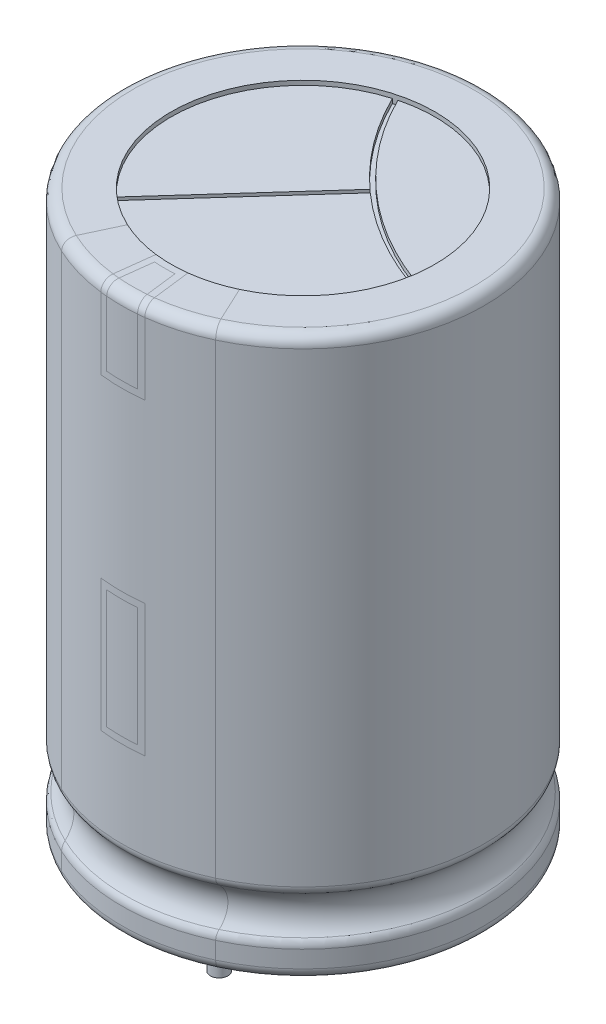
from build123d import *

# Parameters (mm, degrees)
SZKIC2_R                      = 6
WYTNIJ_WYCI_GNI_CIE1_DEPTH    = 0.2
WYTNIJ_WYCI_GNI_CIE2_DEPTH    = 0.2
SZKIC4_R                      = 6
WYTNIJ_WYCI_GNI_CIE3_DEPTH    = 0.5
SZKIC10_R                     = 0.4
DODANIE_WYCI_GNI_CIE1_DEPTH   = 4
DODANIE_WYCI_GNI_CIE1_2_DEPTH = 4
DODANIE_WYCI_GNI_CIE2_DEPTH   = 1.2
DODANIE_WYCI_GNI_CIE2_2_DEPTH = 1.2
SZKIC12_R                     = 4
SZKIC12_R_2                   = 3
WYTNIJ_WYCI_GNI_CIE4_DEPTH    = 0.3
ZAOKR_GLENIE1_R               = 0.05
ZAOKR_GLENIE2_R               = 0.05


with BuildPart() as part:
    # Szkic1 → Obrót1 (revolve)
    with BuildSketch(Plane(origin=(0, 0, 0), x_dir=(0, 0, -1), z_dir=(1, 0, 0))):
        with BuildLine():
            Line((0, 0), (7.75, 0))
            ThreePointArc((7.75, 0), (8.103553391, 0.146446609), (8.25, 0.5))
            Line((8.25, 0.5), (8.25, 1.275255129))
            ThreePointArc((8.25, 1.275255129), (8.21291005, 1.464237365), (8.107142857, 1.625182235))
            ThreePointArc((8.107142857, 1.625182235), (7.75, 2.5), (8.107142857, 3.374817765))
            ThreePointArc((8.107142857, 3.374817765), (8.21291005, 3.535762635), (8.25, 3.724744871))
            Line((8.25, 3.724744871), (8.25, 24.9))
            ThreePointArc((8.25, 24.9), (8.103553391, 25.253553391), (7.75, 25.4))
            Line((7.75, 25.4), (0, 25.4))
            Line((0, 25.4), (0, 0))
        make_face()
    revolve(axis=Axis((0, 25.4, 0), (0, -1, 0)))

    # Szkic2 → Wytnij-wyciągnięcie1 (cut)
    with BuildSketch(Plane(origin=(0, 25.4, 0), x_dir=(1, 0, 0), z_dir=(0, 1, 0))):
        Circle(SZKIC2_R)
    extrude(amount=-WYTNIJ_WYCI_GNI_CIE1_DEPTH, mode=Mode.SUBTRACT)

    # Szkic3 → Wytnij-wyciągnięcie2 (cut)
    with BuildSketch(Plane(origin=(0, 25.2, 0), x_dir=(1, 0, 0), z_dir=(0, 1, 0))):
        with BuildLine():
            Line((1.368369919, 1.670607479), (-4.086590726, -4.39315106))
            ThreePointArc((-4.086590726, -4.39315106), (-4.01280392, -4.460650704), (-3.937902369, -4.526911191))
            Line((-3.937902369, -4.526911191), (1.517058276, 1.536847349))
            ThreePointArc((1.517058276, 1.536847349), (3.58668768, 0.022863948), (5.90219726, -1.078919601))
            ThreePointArc((5.90219726, -1.078919601), (5.919652159, -0.978630837), (5.935403101, -0.878060377))
            ThreePointArc((5.935403101, -0.878060377), (1.576230137, 1.752144438), (-1.498827426, 5.80977765))
            ThreePointArc((-1.498827426, 5.80977765), (-1.59717725, 5.783513191), (-1.69506733, 5.755583962))
            ThreePointArc((-1.69506733, 5.755583962), (-0.355341103, 3.569115293), (1.368369919, 1.670607479))
        make_face()
    extrude(amount=-WYTNIJ_WYCI_GNI_CIE2_DEPTH, mode=Mode.SUBTRACT)

    # Szkic4 → Wytnij-wyciągnięcie3 (cut)
    with BuildSketch(Plane.XZ):
        Circle(SZKIC4_R)
    extrude(amount=-WYTNIJ_WYCI_GNI_CIE3_DEPTH, mode=Mode.SUBTRACT)


with BuildPart() as body_2:
    # Szkic10 → Dodanie-wyciągnięcie1 (new body)
    with BuildSketch(Plane(origin=(0, 0.5, 0), x_dir=(-1, 0, 0), z_dir=(0, -1, 0))):
        with Locations((0, -3.81)):
            Circle(SZKIC10_R)
    extrude(amount=DODANIE_WYCI_GNI_CIE1_DEPTH)


with BuildPart() as body_3:
    # Szkic10 → Dodanie-wyci_gni_cie1 2 (new body)
    with BuildSketch(Plane(origin=(0, 0.5, 0), x_dir=(-1, 0, 0), z_dir=(0, -1, 0))):
        with Locations((0, 3.81)):
            Circle(SZKIC10_R)
    extrude(amount=DODANIE_WYCI_GNI_CIE1_2_DEPTH)


with BuildPart() as body_4:
    # Szkic11 → Dodanie-wyciągnięcie2 (new body)
    with BuildSketch(Plane(origin=(0, 0.5, 0), x_dir=(-1, 0, 0), z_dir=(0, -1, 0))):
        with BuildLine():
            Line((-0.934090555, -3.628920082), (-1.259054317, -4.52175088))
            ThreePointArc((-1.259054317, -4.52175088), (-1.706791557, -4.988117075), (-2.353073698, -4.971221597))
            ThreePointArc((-2.353073698, -4.971221597), (-4.089677513, -3.677572276), (-5.192304065, -1.813829787))
            ThreePointArc((-5.192304065, -1.813829787), (-5.08938791, -1.086893009), (-4.437059837, -0.75))
            Line((-4.437059837, -0.75), (4.437059837, -0.75))
            ThreePointArc((4.437059837, -0.75), (5.08938791, -1.086893009), (5.192304065, -1.813829787))
            ThreePointArc((5.192304065, -1.813829787), (4.089677513, -3.677572276), (2.353073698, -4.971221597))
            ThreePointArc((2.353073698, -4.971221597), (1.706791557, -4.988117075), (1.259054317, -4.52175088))
            Line((1.259054317, -4.52175088), (0.934090555, -3.628920082))
            ThreePointArc((0.934090555, -3.628920082), (0, -2.974862784), (-0.934090555, -3.628920082))
        make_face()
    extrude(amount=DODANIE_WYCI_GNI_CIE2_DEPTH)


with BuildPart() as body_5:
    # Szkic11 → Dodanie-wyci_gni_cie2 2 (new body)
    with BuildSketch(Plane(origin=(0, 0.5, 0), x_dir=(-1, 0, 0), z_dir=(0, -1, 0))):
        with BuildLine():
            Line((-4.437059837, 0.75), (4.437059837, 0.75))
            ThreePointArc((4.437059837, 0.75), (5.08938791, 1.086893009), (5.192304065, 1.813829787))
            ThreePointArc((5.192304065, 1.813829787), (4.089677513, 3.677572276), (2.353073698, 4.971221597))
            ThreePointArc((2.353073698, 4.971221597), (1.706791557, 4.988117075), (1.259054317, 4.52175088))
            Line((1.259054317, 4.52175088), (0.935314887, 3.632283908))
            ThreePointArc((0.935314887, 3.632283908), (0.002495095, 2.978510498), (-0.931462726, 3.630657127))
            Line((-0.931462726, 3.630657127), (-1.258254713, 4.523665192))
            ThreePointArc((-1.258254713, 4.523665192), (-1.706047593, 4.988940616), (-2.351578607, 4.971929008))
            ThreePointArc((-2.351578607, 4.971929008), (-4.089124492, 3.678187174), (-5.192304065, 1.813829787))
            ThreePointArc((-5.192304065, 1.813829787), (-5.08938791, 1.086893009), (-4.437059837, 0.75))
        make_face()
    extrude(amount=DODANIE_WYCI_GNI_CIE2_2_DEPTH)


with BuildPart() as wytnij_wyci_gni_cie4_tool:
    # Szkic12 → Wytnij-wyciągnięcie4 (new body)
    with BuildSketch(Plane(origin=(0, -0.7, 0), x_dir=(-1, 0, 0), z_dir=(0, -1, 0))):
        Circle(SZKIC12_R)
        Circle(SZKIC12_R_2, mode=Mode.SUBTRACT)
    extrude(amount=-WYTNIJ_WYCI_GNI_CIE4_DEPTH)


with BuildPart() as body_5_1:
    add(body_5.part)

    # Wytnij-wyciągnięcie4: cut by wytnij_wyci_gni_cie4_tool
    add(wytnij_wyci_gni_cie4_tool.part, mode=Mode.SUBTRACT)

    # Zaokrąglenie2
    zaokr_glenie2_edges = [body_5_1.edges().sort_by_distance(p)[0] for p in [
        (1.706047593, -0.7, -4.988940616),
        (4.089124492, -0.7, -3.678187174),
        (5.08938791, -0.7, -1.086893009),
        (4.183059124, -0.7, -0.75),
        (-5.08938791, -0.7, -1.086893009),
        (-4.089677513, -0.7, -3.677572276),
        (-1.706791557, -0.7, -4.988117075),
        (-0.001221684, -0.7, -2.978510204),
        (1.138320606, -0.7, -4.195927277),
        (0, -0.7, -0.75),
        (-1.1399937, -0.7, -4.19463445),
        (-4.183059124, -0.7, -0.75),
        (-1.907382861, -0.7, -2.315575657),
        (-2.924950188, -0.7, -2.728491598),
        (2.924051814, -0.7, -2.729454339),
        (1.90643293, -0.7, -2.316357806),
    ]]
    fillet(zaokr_glenie2_edges, radius=ZAOKR_GLENIE2_R)


with BuildPart() as body_4_1:
    add(body_4.part)

    # Wytnij-wyciągnięcie4: cut by wytnij_wyci_gni_cie4_tool
    add(wytnij_wyci_gni_cie4_tool.part, mode=Mode.SUBTRACT)

    # Zaokrąglenie1
    zaokr_glenie1_edges = [body_4_1.edges().sort_by_distance(p)[0] for p in [
        (-1.706791557, -0.7, 4.988117075),
        (-4.089677513, -0.7, 3.677572276),
        (-5.08938791, -0.7, 1.086893009),
        (-4.183059124, -0.7, 0.75),
        (5.08938791, -0.7, 1.086893009),
        (4.089677513, -0.7, 3.677572276),
        (1.706791557, -0.7, 4.988117075),
        (0, -0.7, 2.974862784),
        (-1.1399937, -0.7, 4.19463445),
        (1.1399937, -0.7, 4.19463445),
        (0, -0.7, 0.75),
        (4.183059124, -0.7, 0.75),
        (-1.912504596, -0.7, 2.311347263),
        (-2.924950188, -0.7, 2.728491598),
        (2.924950188, -0.7, 2.728491598),
        (1.912504596, -0.7, 2.311347263),
    ]]
    fillet(zaokr_glenie1_edges, radius=ZAOKR_GLENIE1_R)


solid = Compound([part.part, body_2.part, body_3.part, body_5_1.part, body_4_1.part])
